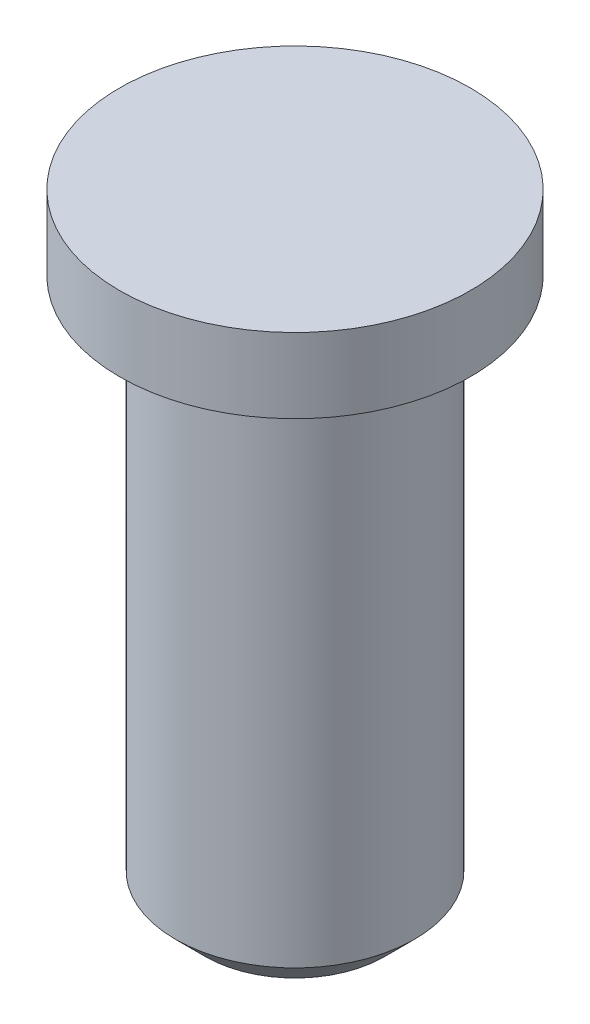
from build123d import *

# Parameters (mm, degrees)
SKETCH1_R           = 8
BOSS_EXTRUDE1_DEPTH = 36.5
CHAMFER1_SIZE       = 2
SKETCH2_R           = 11.75
BOSS_EXTRUDE2_DEPTH = 5


with BuildPart() as part:
    # Sketch1 → Boss-Extrude1 (new body)
    with BuildSketch(Plane(origin=(0, 0, 0), x_dir=(1, 0, 0), z_dir=(0, 1, 0))):
        Circle(SKETCH1_R)
    extrude(amount=BOSS_EXTRUDE1_DEPTH)

    # Chamfer1
    chamfer1_edges = [part.edges().sort_by_distance(p)[0] for p in [
        (-8, 0, 0),
    ]]
    chamfer(chamfer1_edges, length=CHAMFER1_SIZE)

    # Sketch2 → Boss-Extrude2 (add)
    with BuildSketch(Plane(origin=(0, 36.5, 0), x_dir=(1, 0, 0), z_dir=(0, 1, 0))):
        Circle(SKETCH2_R)
    extrude(amount=BOSS_EXTRUDE2_DEPTH)


solid = part.part
